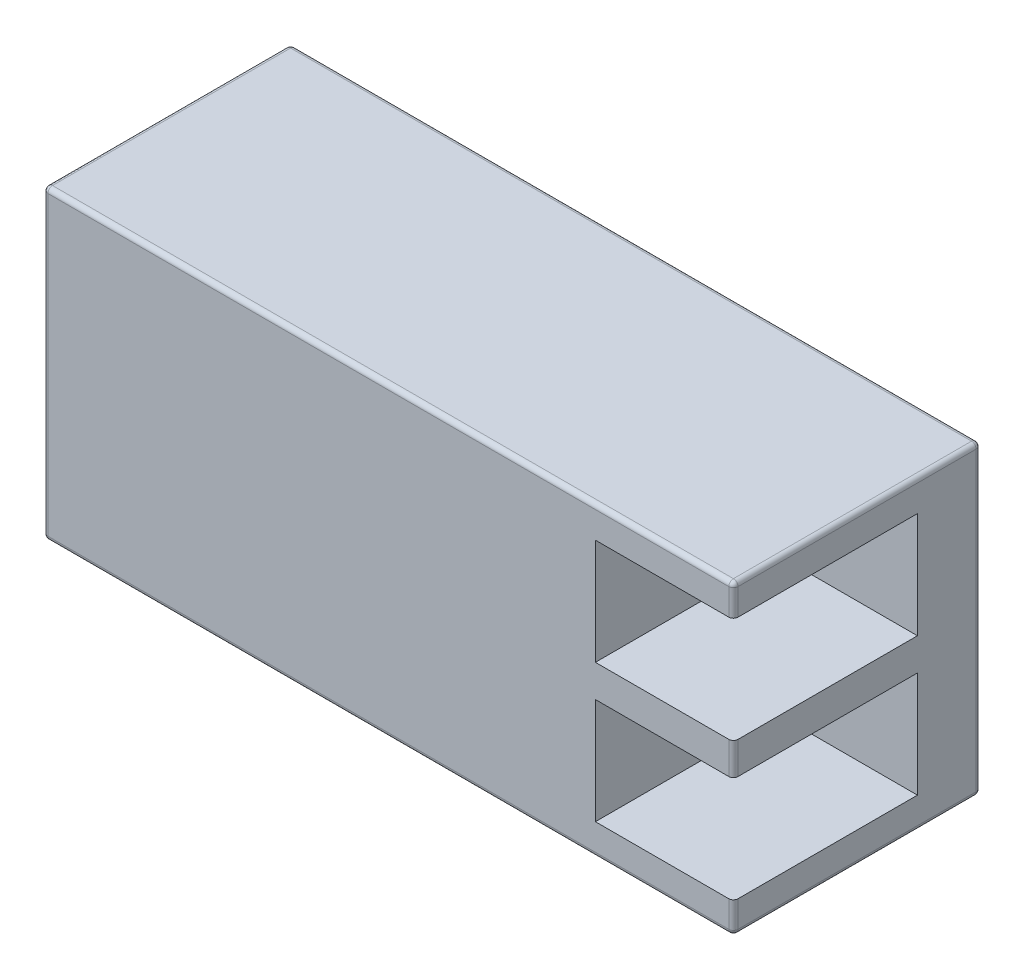
from build123d import *

# Parameters (mm, degrees)
SKETCH1_W           = 30
SKETCH1_H           = 13.3
BOSS_EXTRUDE1_DEPTH = 10.75
SKETCH2_W           = 8
SKETCH2_H           = 4.6
CUT_EXTRUDE1_DEPTH  = 6
FILLET1_R           = 0.2


with BuildPart() as part:
    # Sketch1 → Boss-Extrude1 (new body)
    with BuildSketch(Plane.XY):
        Rectangle(SKETCH1_W, SKETCH1_H)
    extrude(amount=BOSS_EXTRUDE1_DEPTH)

    # Sketch2 → Cut-Extrude1 (cut)
    with BuildSketch(Plane(origin=(15, 0, 0), x_dir=(0, 0, -1), z_dir=(1, 0, 0))):
        with Locations((-6.75, -3)):
            Rectangle(SKETCH2_W, SKETCH2_H)
        with Locations((-6.75, 3)):
            Rectangle(SKETCH2_W, SKETCH2_H)
    extrude(amount=-CUT_EXTRUDE1_DEPTH, mode=Mode.SUBTRACT)

    # Fillet1
    fillet1_edges = [part.edges().sort_by_distance(p)[0] for p in [
        (15, -5.975, 10.75),
        (15, 0, 10.75),
        (15, 5.975, 10.75),
        (0, 6.65, 10.75),
        (-15, 0, 10.75),
        (0, 6.65, 0),
        (15, 0, 0),
        (0, -6.65, 0),
        (-15, 0, 0),
        (-15, 6.65, 5.375),
        (15, 6.65, 5.375),
        (15, -6.65, 5.375),
        (-15, -6.65, 5.375),
        (0, -6.65, 10.75),
    ]]
    fillet(fillet1_edges, radius=FILLET1_R)


solid = part.part
